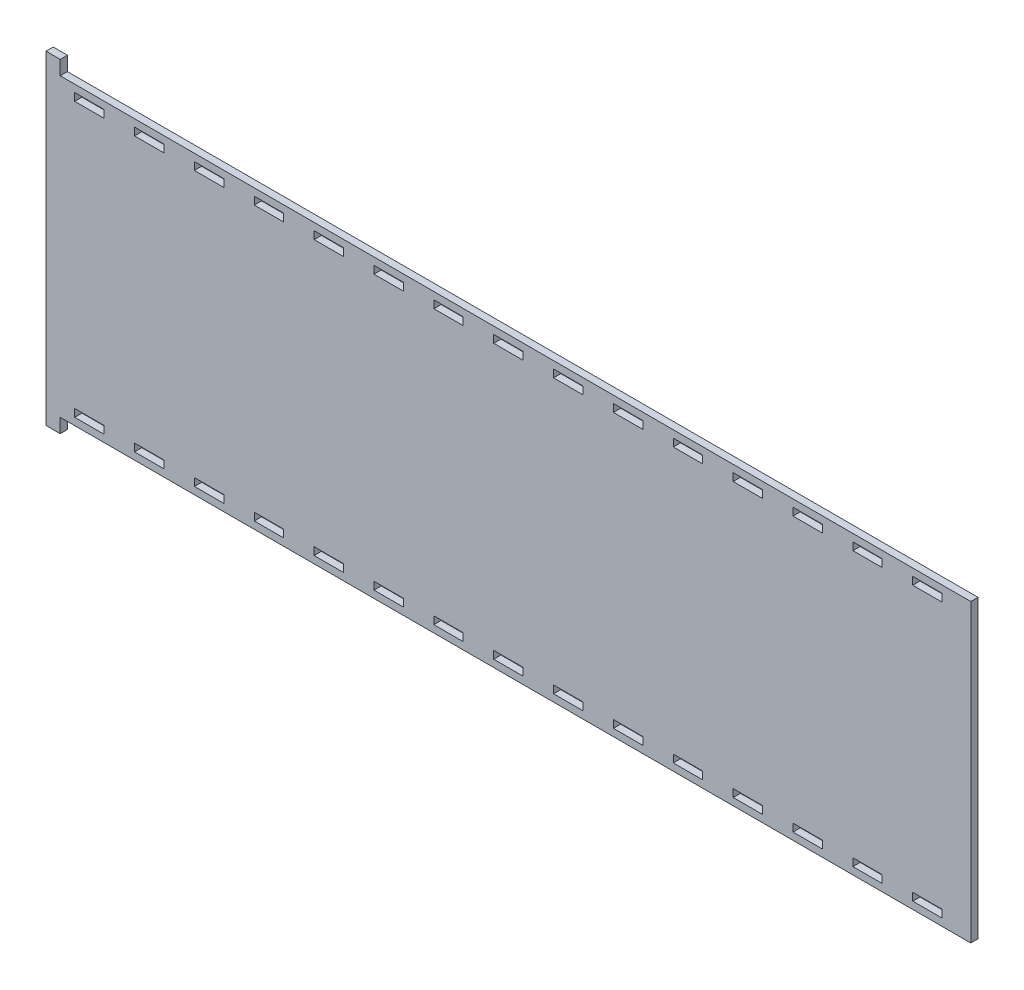
from build123d import *

# Parameters (mm, degrees)
SKETCH1_W           = 12.9
SKETCH1_H           = 3.3782
BOSS_EXTRUDE2_DEPTH = 3.175


with BuildPart() as part:
    # Sketch1 → Boss-Extrude2 (new body)
    with BuildSketch(Plane.XY):
        Polygon((6.2500002, -9.525), (6.2500002, -3.2782), (406.4, -3.2782), (406.4, 126.6968), (6.2500002, 126.6968), (6.2500002, 132.9436), (0, 132.9436), (0, -9.525), align=None)
        with Locations((19.05, 121.8327)):
            Rectangle(SKETCH1_W, SKETCH1_H, mode=Mode.SUBTRACT)
        with Locations((45.357142857, 121.8327)):
            Rectangle(SKETCH1_W, SKETCH1_H, mode=Mode.SUBTRACT)
        with Locations((387.35, 121.8327)):
            Rectangle(SKETCH1_W, SKETCH1_H, mode=Mode.SUBTRACT)
        with Locations((361.042857143, 121.8327)):
            Rectangle(SKETCH1_W, SKETCH1_H, mode=Mode.SUBTRACT)
        with Locations((71.664285714, 121.8327)):
            Rectangle(SKETCH1_W, SKETCH1_H, mode=Mode.SUBTRACT)
        with Locations((97.971428571, 121.8327)):
            Rectangle(SKETCH1_W, SKETCH1_H, mode=Mode.SUBTRACT)
        with Locations((124.278571429, 121.8327)):
            Rectangle(SKETCH1_W, SKETCH1_H, mode=Mode.SUBTRACT)
        with Locations((150.585714286, 121.8327)):
            Rectangle(SKETCH1_W, SKETCH1_H, mode=Mode.SUBTRACT)
        with Locations((176.892857143, 121.8327)):
            Rectangle(SKETCH1_W, SKETCH1_H, mode=Mode.SUBTRACT)
        with Locations((203.2, 121.8327)):
            Rectangle(SKETCH1_W, SKETCH1_H, mode=Mode.SUBTRACT)
        with Locations((229.507142857, 121.8327)):
            Rectangle(SKETCH1_W, SKETCH1_H, mode=Mode.SUBTRACT)
        with Locations((255.814285714, 121.8327)):
            Rectangle(SKETCH1_W, SKETCH1_H, mode=Mode.SUBTRACT)
        with Locations((282.121428571, 121.8327)):
            Rectangle(SKETCH1_W, SKETCH1_H, mode=Mode.SUBTRACT)
        with Locations((308.428571429, 121.8327)):
            Rectangle(SKETCH1_W, SKETCH1_H, mode=Mode.SUBTRACT)
        with Locations((334.735714286, 121.8327)):
            Rectangle(SKETCH1_W, SKETCH1_H, mode=Mode.SUBTRACT)
        with Locations((387.35, 1.5859)):
            Rectangle(SKETCH1_W, SKETCH1_H, mode=Mode.SUBTRACT)
        with Locations((361.042857143, 1.5859)):
            Rectangle(SKETCH1_W, SKETCH1_H, mode=Mode.SUBTRACT)
        with Locations((334.735714286, 1.5859)):
            Rectangle(SKETCH1_W, SKETCH1_H, mode=Mode.SUBTRACT)
        with Locations((308.428571429, 1.5859)):
            Rectangle(SKETCH1_W, SKETCH1_H, mode=Mode.SUBTRACT)
        with Locations((282.121428571, 1.5859)):
            Rectangle(SKETCH1_W, SKETCH1_H, mode=Mode.SUBTRACT)
        with Locations((255.814285714, 1.5859)):
            Rectangle(SKETCH1_W, SKETCH1_H, mode=Mode.SUBTRACT)
        with Locations((229.507142857, 1.5859)):
            Rectangle(SKETCH1_W, SKETCH1_H, mode=Mode.SUBTRACT)
        with Locations((203.2, 1.5859)):
            Rectangle(SKETCH1_W, SKETCH1_H, mode=Mode.SUBTRACT)
        with Locations((176.892857143, 1.5859)):
            Rectangle(SKETCH1_W, SKETCH1_H, mode=Mode.SUBTRACT)
        with Locations((150.585714286, 1.5859)):
            Rectangle(SKETCH1_W, SKETCH1_H, mode=Mode.SUBTRACT)
        with Locations((124.278571429, 1.5859)):
            Rectangle(SKETCH1_W, SKETCH1_H, mode=Mode.SUBTRACT)
        with Locations((97.971428571, 1.5859)):
            Rectangle(SKETCH1_W, SKETCH1_H, mode=Mode.SUBTRACT)
        with Locations((71.664285714, 1.5859)):
            Rectangle(SKETCH1_W, SKETCH1_H, mode=Mode.SUBTRACT)
        with Locations((45.357142857, 1.5859)):
            Rectangle(SKETCH1_W, SKETCH1_H, mode=Mode.SUBTRACT)
        with Locations((19.05, 1.5859)):
            Rectangle(SKETCH1_W, SKETCH1_H, mode=Mode.SUBTRACT)
    extrude(amount=BOSS_EXTRUDE2_DEPTH)


solid = part.part
